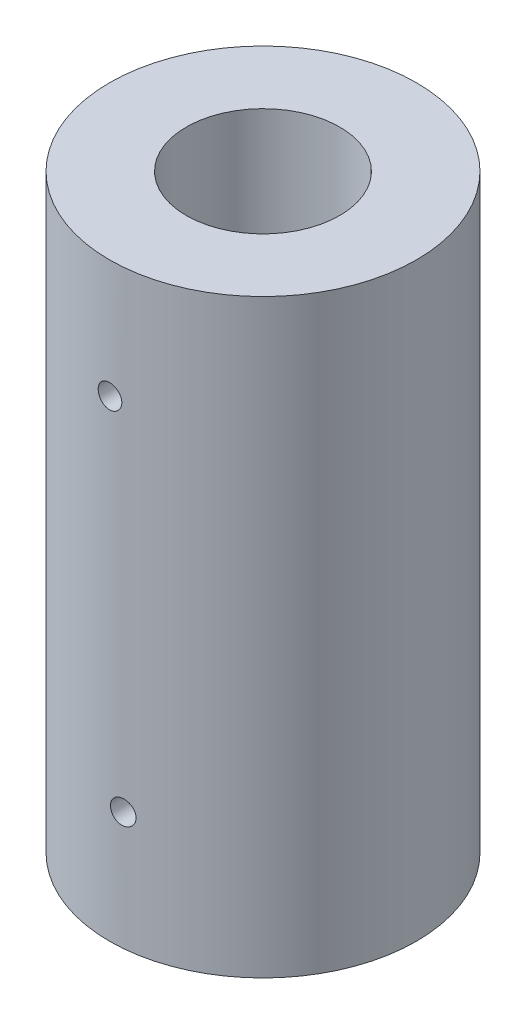
from build123d import *

# Parameters (mm, degrees)
SKETCH1_R           = 13
SKETCH1_R_2         = 6.5
BOSS_EXTRUDE1_DEPTH = 50
SKETCH3_R           = 1
CUT_EXTRUDE1_DEPTH  = 73


with BuildPart() as part:
    # Sketch1 → Boss-Extrude1 (new body)
    with BuildSketch(Plane(origin=(0, 0, 0), x_dir=(1, 0, 0), z_dir=(0, 1, 0))):
        Circle(SKETCH1_R)
        Circle(SKETCH1_R_2, mode=Mode.SUBTRACT)
    extrude(amount=BOSS_EXTRUDE1_DEPTH)

    # Sketch3 → Cut-Extrude1 (cut)
    with BuildSketch(Plane(origin=(0, 50, 13), x_dir=(1, 0, 0), z_dir=(0, 0, 1))):
        with Locations((0, -10)):
            Circle(SKETCH3_R)
        with Locations((1.077748206, -40)):
            Circle(SKETCH3_R)
    extrude(amount=-CUT_EXTRUDE1_DEPTH, mode=Mode.SUBTRACT)


solid = part.part
